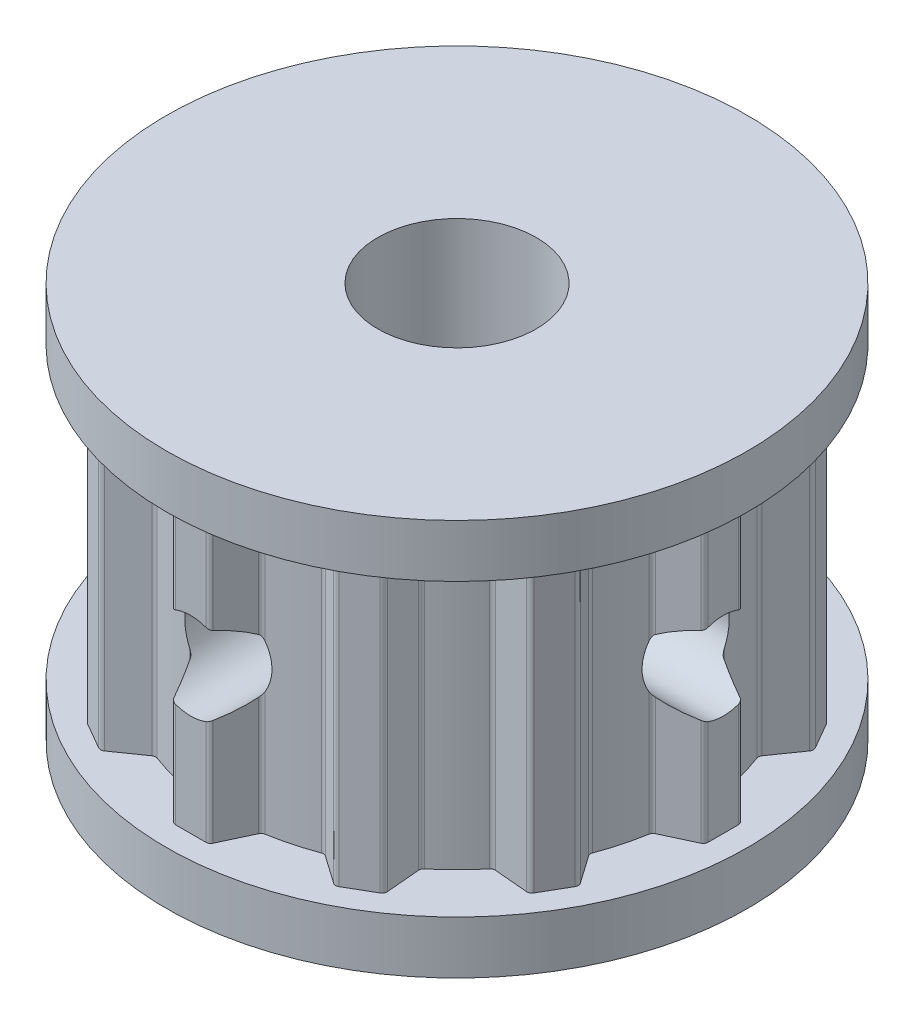
from build123d import *

# Parameters (mm, degrees)
SKETCH_1_R                       = 8.81
EXTRUDE_1_DEPTH                  = 5.5
EXTRUDE_1_DEPTH_BACK             = 5.5
EXTRUDE_5_DEPTH                  = 11
FILLET_1_R                       = 0.19
PATTERN_CIRCULAR_1_COUNT         = 12
FILLET_1_OF_PATTERN_CIRCULAR_1_R = 0.19
SKETCH_3_R                       = 11
EXTRUDE_3_DEPTH                  = 2
SKETCH_4_R                       = 11
EXTRUDE_4_DEPTH                  = 2
SKETCH_5_R                       = 3
CUT_EXTRUDE_1_DEPTH              = 22.610182785
M4X0_7_TAPPED_HOLE1_REACH        = 27.715
M4X0_7_TAPPED_HOLE1_BORE_R       = 1.65
CIRPATTERN1_COUNT                = 2
CIRPATTERN1_ANGLE                = 90


with BuildPart() as part:
    # Sketch 1 → Extrude 1 (new, two sides)
    with BuildSketch(Plane(origin=(0, 0, 0), x_dir=(1, 0, 0), z_dir=(0, 1, 0))) as extrude_1_sk:
        with Locations(Location((0, 0, 0), (0, 0, 270))):
            Circle(SKETCH_1_R)
    extrude(amount=EXTRUDE_1_DEPTH)
    extrude(extrude_1_sk.sketch, amount=-EXTRUDE_1_DEPTH_BACK)

    # Sketch 7 → Extrude 5 (add)
    with BuildSketch(Plane.XZ.offset(5.5)):
        Polygon((-1.751307658, -7.81), (1.751307658, -7.81), (0.692789274, -10.08), (-0.692789274, -10.08), align=None)
    extrude_5 = extrude(amount=-EXTRUDE_5_DEPTH)

    # Fillet 1
    fillet_1_edges = [part.edges().sort_by_distance(p)[0] for p in [
        (1.332243049, 0, -8.708686954),
        (0.692789274, 0, -10.08),
        (-1.332243049, 0, -8.708686954),
        (-0.692789274, 0, -10.08),
    ]]
    fillet(fillet_1_edges, radius=FILLET_1_R)

    # Pattern Circular 1: Extrude 5 ×12 about axis
    pattern_circular_1_axis = Axis((0, 0, 0), (0, 1, 0))
    for i in range(1, PATTERN_CIRCULAR_1_COUNT):
        add(extrude_5.rotate(pattern_circular_1_axis, i * 360 / PATTERN_CIRCULAR_1_COUNT))

    # Fillet 1 of Pattern Circular 1
    fillet_1_of_pattern_circular_1_edges = [part.edges().sort_by_distance(p)[0] for p in [
        (-3.200587152, 0, -8.20806566),
        (-4.440026889, 0, -9.075930707),
        (-5.508099802, 0, -6.875822611),
        (-5.639973111, 0, -8.383141433),
        (-6.875822611, 0, -5.508099802),
        (-8.383141433, 0, -5.639973111),
        (-8.20806566, 0, -3.200587152),
        (-9.075930707, 0, -4.440026889),
        (-8.708686954, 0, -1.332243049),
        (-10.08, 0, -0.692789274),
        (-8.708686954, 0, 1.332243049),
        (-10.08, 0, 0.692789274),
        (-8.20806566, 0, 3.200587152),
        (-9.075930707, 0, 4.440026889),
        (-6.875822611, 0, 5.508099802),
        (-8.383141433, 0, 5.639973111),
        (-5.508099802, 0, 6.875822611),
        (-5.639973111, 0, 8.383141433),
        (-3.200587152, 0, 8.20806566),
        (-4.440026889, 0, 9.075930707),
        (-1.332243049, 0, 8.708686954),
        (-0.692789274, 0, 10.08),
        (1.332243049, 0, 8.708686954),
        (0.692789274, 0, 10.08),
        (3.200587152, 0, 8.20806566),
        (4.440026889, 0, 9.075930707),
        (5.508099802, 0, 6.875822611),
        (5.639973111, 0, 8.383141433),
        (6.875822611, 0, 5.508099802),
        (8.383141433, 0, 5.639973111),
        (8.20806566, 0, 3.200587152),
        (9.075930707, 0, 4.440026889),
        (8.708686954, 0, 1.332243049),
        (10.08, 0, 0.692789274),
        (8.708686954, 0, -1.332243049),
        (10.08, 0, -0.692789274),
        (8.20806566, 0, -3.200587152),
        (9.075930707, 0, -4.440026889),
        (6.875822611, 0, -5.508099802),
        (8.383141433, 0, -5.639973111),
        (5.508099802, 0, -6.875822611),
        (5.639973111, 0, -8.383141433),
        (3.200587152, 0, -8.20806566),
        (4.440026889, 0, -9.075930707),
    ]]
    fillet(fillet_1_of_pattern_circular_1_edges, radius=FILLET_1_OF_PATTERN_CIRCULAR_1_R)

    # Sketch 3 → Extrude 3 (add)
    with BuildSketch(Plane.XZ.offset(5.5)):
        with Locations(Location((0, 0, 0), (0, 0, 270))):
            Circle(SKETCH_3_R)
    extrude(amount=EXTRUDE_3_DEPTH)

    # Sketch 4 → Extrude 4 (add)
    with BuildSketch(Plane(origin=(0, 5.5, 0), x_dir=(1, 0, 0), z_dir=(0, 1, 0))):
        with Locations(Location((0, 0, 0), (0, 0, 90))):
            Circle(SKETCH_4_R)
    extrude(amount=EXTRUDE_4_DEPTH)

    # Sketch 5 → Cut-Extrude 1 (cut, through all)
    with BuildSketch(Plane.XZ.offset(7.5)):
        with Locations(Location((0, 0, 0), (0, 0, 270))):
            Circle(SKETCH_5_R)
    extrude(amount=-CUT_EXTRUDE_1_DEPTH, mode=Mode.SUBTRACT)

    # M4x0.7 Tapped Hole1 bore → M4x0.7 Tapped Hole1 (cut, up to next)
    with BuildSketch(Plane.XY.offset(11), mode=Mode.PRIVATE) as m4x0_7_tapped_hole1_sk1:
        Circle(M4X0_7_TAPPED_HOLE1_BORE_R)
    m4x0_7_tapped_hole1_tool1 = extrude(m4x0_7_tapped_hole1_sk1.sketch, amount=-M4X0_7_TAPPED_HOLE1_REACH, mode=Mode.PRIVATE) & part.part
    m4x0_7_tapped_hole1 = m4x0_7_tapped_hole1_tool1.solids().sort_by_distance((0, 0, 11))[0]
    add(m4x0_7_tapped_hole1, mode=Mode.SUBTRACT)

    # CirPattern1: M4x0.7 Tapped Hole1 ×2 about axis
    cirpattern1_axis = Axis((0, 7.5, 0), (0, 1, 0))
    for i in range(1, CIRPATTERN1_COUNT):
        add(m4x0_7_tapped_hole1.rotate(cirpattern1_axis, i * CIRPATTERN1_ANGLE / (CIRPATTERN1_COUNT - 1)), mode=Mode.SUBTRACT)


solid = part.part
